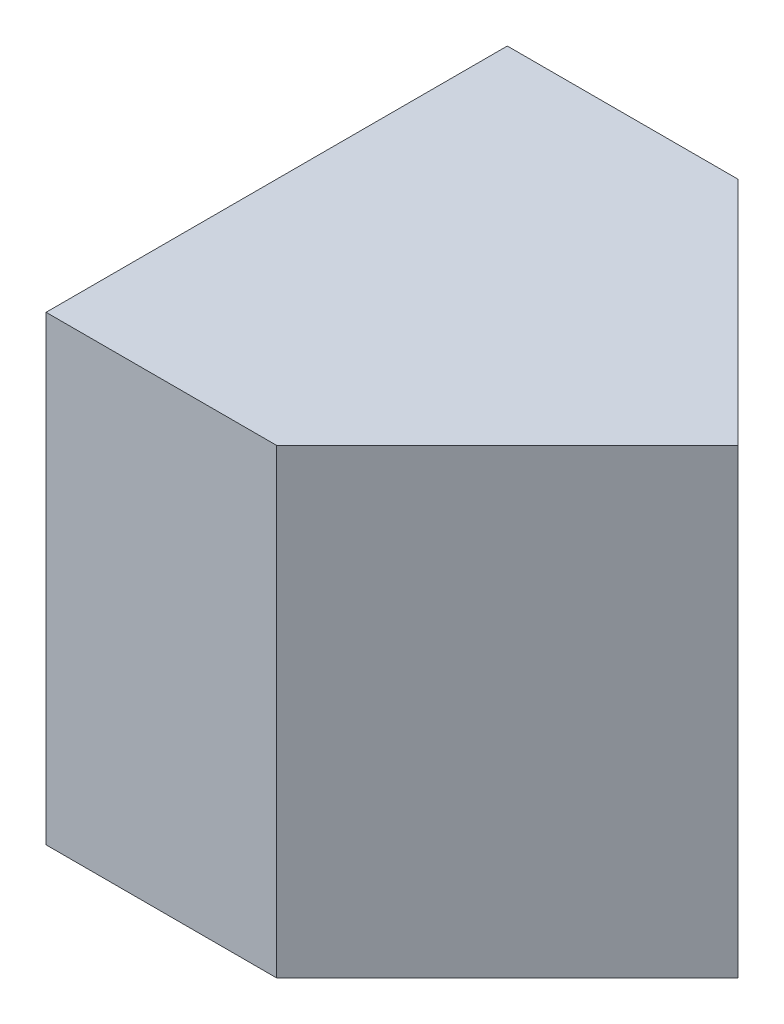
from build123d import *

# Parameters (mm, degrees)
SKETCH1_W           = 20
SKETCH1_H           = 20
BOSS_EXTRUDE1_DEPTH = 20
CUT_EXTRUDE1_DEPTH  = 20
CUT_EXTRUDE2_DEPTH  = 20


with BuildPart() as part:
    # Sketch1 → Boss-Extrude1 (new body)
    with BuildSketch(Plane.XY):
        with Locations((10, 10)):
            Rectangle(SKETCH1_W, SKETCH1_H)
    extrude(amount=BOSS_EXTRUDE1_DEPTH)

    # Sketch2 → Cut-Extrude1 (cut)
    with BuildSketch(Plane(origin=(0, 20, 0), x_dir=(1, 0, 0), z_dir=(0, 1, 0))):
        Polygon((20, 0), (10, 0), (20, -10), align=None)
    extrude(amount=-CUT_EXTRUDE1_DEPTH, mode=Mode.SUBTRACT)

    # Sketch3 → Cut-Extrude2 (cut)
    with BuildSketch(Plane(origin=(0, 20, 0), x_dir=(1, 0, 0), z_dir=(0, 1, 0))):
        Polygon((20, -20), (10, -20), (20, -10), align=None)
    extrude(amount=-CUT_EXTRUDE2_DEPTH, mode=Mode.SUBTRACT)


solid = part.part
